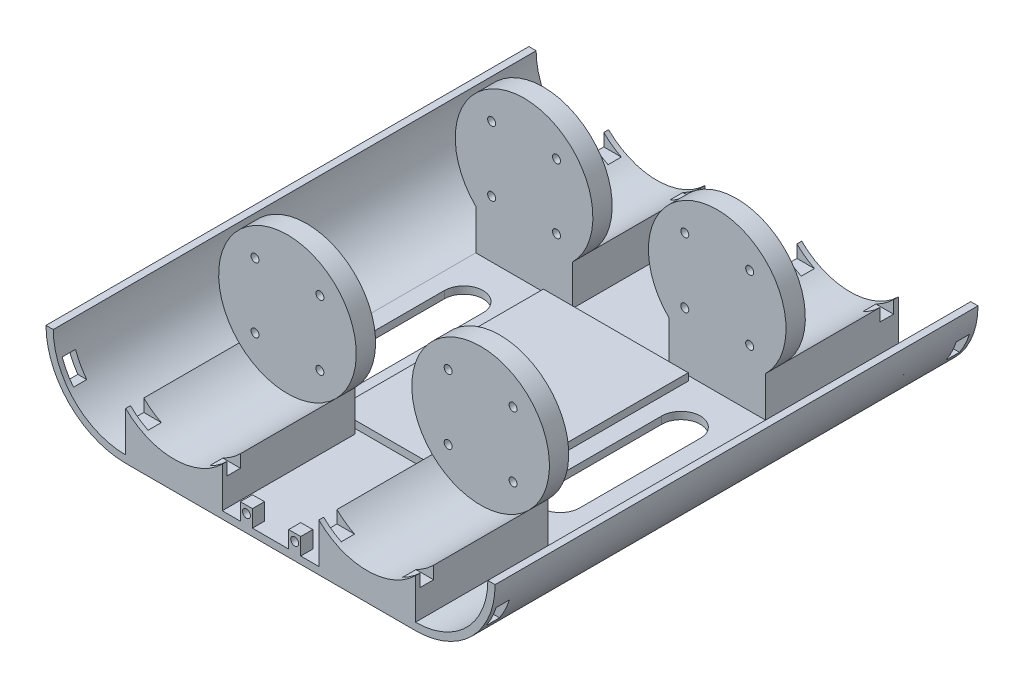
from build123d import *

# Parameters (mm, degrees)
SKETCH_1_W               = 120
SKETCH_1_H               = 200
EXTRUDE_1_DEPTH          = 3
SKETCH_3_W               = 200
SKETCH_3_H               = 3
REVOLVE_1_ANGLE          = 90
SKETCH_5_W               = 200
SKETCH_5_H               = 3
REVOLVE_2_ANGLE          = 90
EXTRUDE_4_DEPTH          = 55
SKETCH_7_6_R             = 28.5
CUT_EXTRUDE_1_DEPTH      = 47
SKETCH_9_R               = 1.65
CUT_EXTRUDE_2_DEPTH      = 47
SKETCH_10_R              = 1.65
CUT_EXTRUDE_3_DEPTH      = 47
EXTRUDE_START            = -55
EXTRUDE_5_DEPTH          = 55
CUT_EXTRUDE_START        = -47
SKETCH_11_3_R            = 28.5
CUT_EXTRUDE_4_DEPTH      = 47
SKETCH_14_R              = 1.65
CUT_EXTRUDE_5_DEPTH      = 47
SKETCH_15_W              = 60
SKETCH_15_H              = 86
EXTRUDE_6_DEPTH          = 3
SKETCH_17_W              = 5
SKETCH_17_H              = 10
SKETCH_17_R              = 1.65
EXTRUDE_7_DEPTH          = 5
EXTRUDE_START_2          = -5
SKETCH_18_W              = 5
SKETCH_18_H              = 10
SKETCH_18_R              = 1.65
EXTRUDE_8_DEPTH          = 5
CUT_EXTRUDE_6_DEPTH      = 11
CUT_EXTRUDE_7_DEPTH      = 108
CUT_EXTRUDE_7_DEPTH_BACK = 119
SKETCH_20_W              = 5.5
SKETCH_20_H              = 8.5


with BuildPart() as part:
    # 草图1 → 凸台-拉伸1 (new body)
    with BuildSketch(Plane(origin=(0, 0, 0), x_dir=(1, 0, 0), z_dir=(0, 1, 0))):
        Rectangle(SKETCH_1_W, SKETCH_1_H)
    extrude(amount=EXTRUDE_1_DEPTH)

    # 草图3 → 旋转1 (revolve)
    with BuildSketch(Plane(origin=(60, 0, 0), x_dir=(0, 0, -1), z_dir=(1, 0, 0))):
        with Locations((0, 1.5)):
            Rectangle(SKETCH_3_W, SKETCH_3_H)
    revolve(axis=Axis((60, 33, 100), (0, 0, 1)), revolution_arc=REVOLVE_1_ANGLE)

    # 草图5 → 旋转2 (revolve)
    with BuildSketch(Plane.ZY.offset(60)):
        with Locations((0, 1.5)):
            Rectangle(SKETCH_5_W, SKETCH_5_H)
    revolve(axis=Axis((-60, 33, -100), (0, 0, -1)), revolution_arc=REVOLVE_2_ANGLE)

    # 草图7 → 凸台-拉伸4 (add)
    with BuildSketch(Plane.XY.offset(100)):
        with BuildLine():
            Line((60, 3), (60, 19.696059496))
            ThreePointArc((60, 19.696059496), (40, 68.5), (20, 19.696059496))
            Line((20, 19.696059496), (20, 3))
            Line((20, 3), (60, 3))
        make_face()
        with BuildLine():
            ThreePointArc((-20, 19.696059496), (-40, 68.5), (-60, 19.696059496))
            Line((-60, 19.696059496), (-60, 3))
            Line((-60, 3), (-20, 3))
            Line((-20, 3), (-20, 19.696059496))
        make_face()
    extrude(amount=-EXTRUDE_4_DEPTH)

    # 草图7<6> → 切除-拉伸1 (cut)
    with BuildSketch(Plane.XY.offset(100)):
        with Locations((40, 40)):
            Circle(SKETCH_7_6_R)
        with Locations((-40, 40)):
            Circle(SKETCH_7_6_R)
    extrude(amount=-CUT_EXTRUDE_1_DEPTH, mode=Mode.SUBTRACT)

    # 草图9 → 切除-拉伸2 (cut)
    with BuildSketch(Plane(origin=(0, 0, 45), x_dir=(-1, 0, 0), z_dir=(0, 0, -1))):
        with Locations((-53.435028843, 53.435028843)):
            Circle(SKETCH_9_R)
        with Locations((-26.564971157, 53.435028843)):
            Circle(SKETCH_9_R)
        with Locations((-26.564971157, 26.564971157)):
            Circle(SKETCH_9_R)
        with Locations((-53.435028843, 26.564971157)):
            Circle(SKETCH_9_R)
    extrude(amount=-CUT_EXTRUDE_2_DEPTH, mode=Mode.SUBTRACT)

    # 草图10 → 切除-拉伸3 (cut)
    with BuildSketch(Plane(origin=(0, 0, 45), x_dir=(-1, 0, 0), z_dir=(0, 0, -1))):
        with Locations((26.564971157, 53.435028843)):
            Circle(SKETCH_10_R)
        with Locations((53.435028843, 53.435028843)):
            Circle(SKETCH_10_R)
        with Locations((53.435028843, 26.564971157)):
            Circle(SKETCH_10_R)
        with Locations((26.564971157, 26.564971157)):
            Circle(SKETCH_10_R)
    extrude(amount=-CUT_EXTRUDE_3_DEPTH, mode=Mode.SUBTRACT)

    # 草图11 → 凸台-拉伸5 (add)
    with BuildSketch(Plane(origin=(0, 0, -100), x_dir=(-1, 0, 0), z_dir=(0, 0, -1)).offset(EXTRUDE_START)):
        with BuildLine():
            Line((-20, 3), (-20, 19.696059496))
            ThreePointArc((-20, 19.696059496), (-40, 68.5), (-60, 19.696059496))
            Line((-60, 19.696059496), (-60, 3))
            Line((-60, 3), (-20, 3))
        make_face()
        with BuildLine():
            Line((20, 19.696059496), (20, 3))
            Line((20, 3), (60, 3))
            Line((60, 3), (60, 19.696059496))
            ThreePointArc((60, 19.696059496), (40, 68.5), (20, 19.696059496))
        make_face()
    extrude(amount=EXTRUDE_5_DEPTH)

    # 草图11<3> → 切除-拉伸4 (cut)
    with BuildSketch(Plane(origin=(0, 0, -100), x_dir=(-1, 0, 0), z_dir=(0, 0, -1)).offset(CUT_EXTRUDE_START)):
        with Locations((-40, 40)):
            Circle(SKETCH_11_3_R)
        with Locations((40, 40)):
            Circle(SKETCH_11_3_R)
    extrude(amount=CUT_EXTRUDE_4_DEPTH, mode=Mode.SUBTRACT)

    # 草图14 → 切除-拉伸5 (cut)
    with BuildSketch(Plane(origin=(0, 0, -53), x_dir=(-1, 0, 0), z_dir=(0, 0, -1))):
        with Locations((-26.564971157, 53.435028843)):
            Circle(SKETCH_14_R)
        with Locations((26.564971157, 53.435028843)):
            Circle(SKETCH_14_R)
        with Locations((-26.564971157, 26.564971157)):
            Circle(SKETCH_14_R)
        with Locations((-53.435028843, 26.564971157)):
            Circle(SKETCH_14_R)
        with Locations((-53.435028843, 53.435028843)):
            Circle(SKETCH_14_R)
        with Locations((53.435028843, 53.435028843)):
            Circle(SKETCH_14_R)
        with Locations((53.435028843, 26.564971157)):
            Circle(SKETCH_14_R)
        with Locations((26.564971157, 26.564971157)):
            Circle(SKETCH_14_R)
    extrude(amount=-CUT_EXTRUDE_5_DEPTH, mode=Mode.SUBTRACT)

    # 草图15 → 凸台-拉伸6 (add)
    with BuildSketch(Plane(origin=(0, 3, 0), x_dir=(1, 0, 0), z_dir=(0, 1, 0))):
        Rectangle(SKETCH_15_W, SKETCH_15_H)
    extrude(amount=EXTRUDE_6_DEPTH)

    # 草图17 → 凸台-拉伸7 (add)
    # profile 1 of 2: a face of its own
    with BuildSketch(Plane.XY.offset(100)):
        with Locations((-10, 5)):
            Rectangle(SKETCH_17_W, SKETCH_17_H)
        with Locations((-10, 7)):
            Circle(SKETCH_17_R, mode=Mode.SUBTRACT)
    # profile 2 of 2: a face of its own
    with BuildSketch(Plane.XY.offset(100)):
        with Locations((10, 5)):
            Rectangle(SKETCH_17_W, SKETCH_17_H)
        with Locations((10, 7)):
            Circle(SKETCH_17_R, mode=Mode.SUBTRACT)
    extrude(amount=-EXTRUDE_7_DEPTH)

    # 草图18 → 凸台-拉伸8 (add)
    # profile 1 of 2: a face of its own
    with BuildSketch(Plane(origin=(0, 0, -100), x_dir=(-1, 0, 0), z_dir=(0, 0, -1)).offset(EXTRUDE_START_2)):
        with Locations((-10, 5)):
            Rectangle(SKETCH_18_W, SKETCH_18_H)
        with Locations((-10, 7)):
            Circle(SKETCH_18_R, mode=Mode.SUBTRACT)
    # profile 2 of 2: a face of its own
    with BuildSketch(Plane(origin=(0, 0, -100), x_dir=(-1, 0, 0), z_dir=(0, 0, -1)).offset(EXTRUDE_START_2)):
        with Locations((10, 5)):
            Rectangle(SKETCH_18_W, SKETCH_18_H)
        with Locations((10, 7)):
            Circle(SKETCH_18_R, mode=Mode.SUBTRACT)
    extrude(amount=EXTRUDE_8_DEPTH)

    # 草图19 → 切除-拉伸6 (cut)
    with BuildSketch(Plane(origin=(0, 3, 0), x_dir=(1, 0, 0), z_dir=(0, 1, 0))):
        with BuildLine():
            Line((-53, -25), (-53, 25))
            ThreePointArc((-53, 25), (-45, 33), (-37, 25))
            Line((-37, 25), (-37, -25))
            ThreePointArc((-37, -25), (-45, -33), (-53, -25))
        make_face()
        with BuildLine():
            Line((37, -25), (37, 25))
            ThreePointArc((37, 25), (45, 33), (53, 25))
            Line((53, 25), (53, -25))
            ThreePointArc((53, -25), (45, -33), (37, -25))
        make_face()
    extrude(amount=-CUT_EXTRUDE_6_DEPTH, mode=Mode.SUBTRACT)

    # 草图20 → 切除-拉伸7 (cut, two sides: drawn at the far end of the back side and taken through both)
    with BuildSketch(Plane(origin=(0, 0, 0), x_dir=(0, 0, -1), z_dir=(1, 0, 0)).offset(-CUT_EXTRUDE_7_DEPTH_BACK)):
        with Locations((-95.25, 18.75)):
            Rectangle(SKETCH_20_W, SKETCH_20_H)
        with Locations((95.25, 18.75)):
            Rectangle(SKETCH_20_W, SKETCH_20_H)
    extrude(amount=CUT_EXTRUDE_7_DEPTH + CUT_EXTRUDE_7_DEPTH_BACK, mode=Mode.SUBTRACT)


solid = part.part
